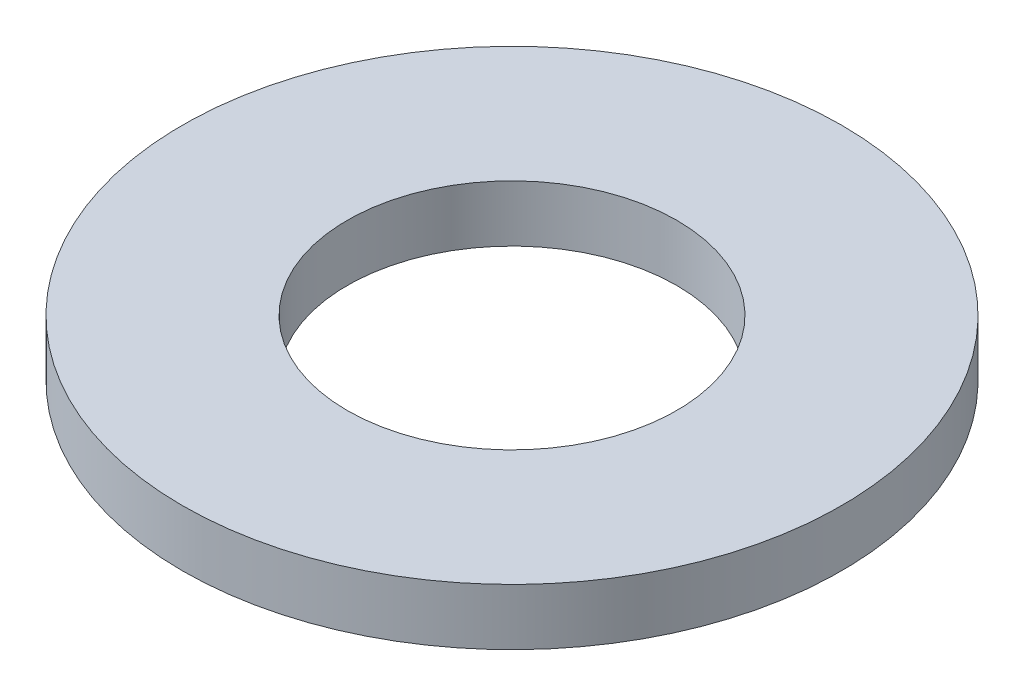
from build123d import *

# Parameters (mm, degrees)
SKETCH1_R           = 35
SKETCH1_R_2         = 17.5
BOSS_EXTRUDE1_DEPTH = 6


with BuildPart() as part:
    # Sketch1 → Boss-Extrude1 (new body)
    with BuildSketch(Plane(origin=(0, 0, 0), x_dir=(1, 0, 0), z_dir=(0, 1, 0))):
        Circle(SKETCH1_R)
        Circle(SKETCH1_R_2, mode=Mode.SUBTRACT)
    extrude(amount=BOSS_EXTRUDE1_DEPTH)


solid = part.part
